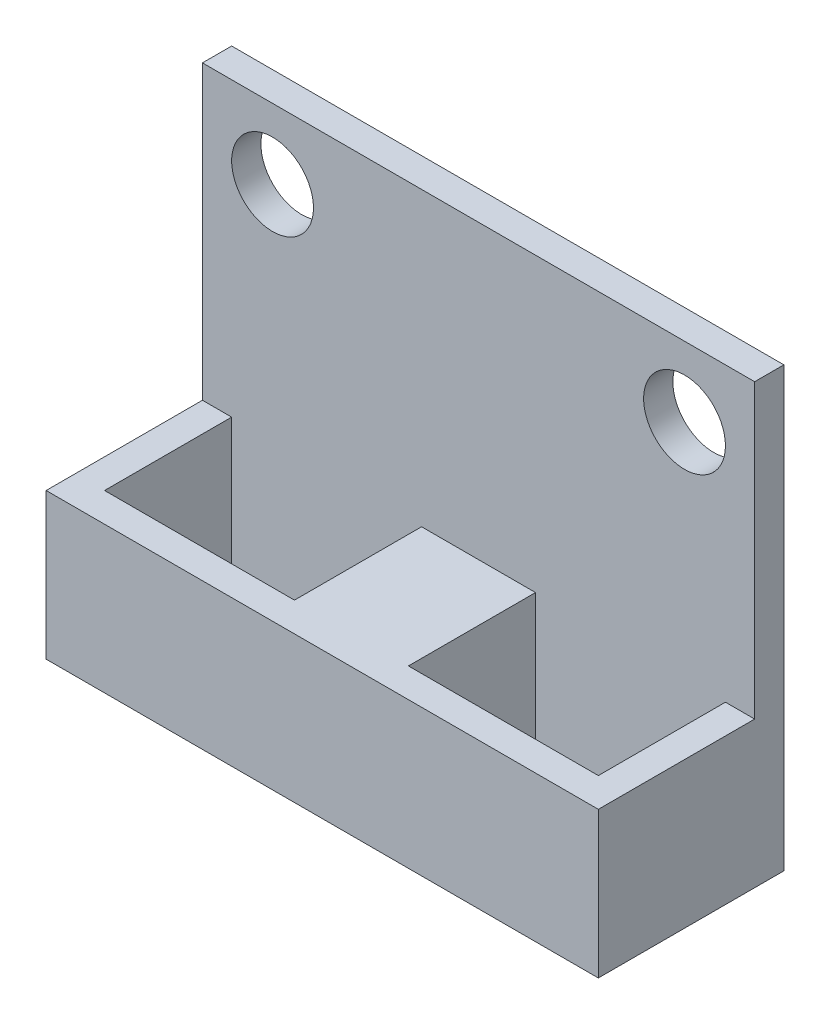
from build123d import *

# Parameters (mm, degrees)
SKETCH1_W           = 18.9
SKETCH1_H           = 6.35
SKETCH1_W_2         = 6.5
SKETCH1_H_2         = 4.35
BOSS_EXTRUDE1_DEPTH = 5
SKETCH2_W           = 18.9
SKETCH2_H           = 1
BOSS_EXTRUDE2_DEPTH = 10
SKETCH3_R           = 1.4
CUT_EXTRUDE1_DEPTH  = 2


with BuildPart() as part:
    # Sketch1 → Boss-Extrude1 (new body)
    with BuildSketch(Plane(origin=(0, 0, 0), x_dir=(1, 0, 0), z_dir=(0, 1, 0))):
        Rectangle(SKETCH1_W, SKETCH1_H)
        with Locations((-5.2, 0)):
            Rectangle(SKETCH1_W_2, SKETCH1_H_2, mode=Mode.SUBTRACT)
        with Locations((5.2, 0)):
            Rectangle(SKETCH1_W_2, SKETCH1_H_2, mode=Mode.SUBTRACT)
    extrude(amount=BOSS_EXTRUDE1_DEPTH)

    # Sketch2 → Boss-Extrude2 (add)
    with BuildSketch(Plane(origin=(0, 5, 0), x_dir=(1, 0, 0), z_dir=(0, 1, 0))):
        with Locations((0, 2.675)):
            Rectangle(SKETCH2_W, SKETCH2_H)
    extrude(amount=BOSS_EXTRUDE2_DEPTH)

    # Sketch3 → Cut-Extrude1 (cut, through all)
    with BuildSketch(Plane.XY.offset(-2.175)):
        with Locations((7.05, 12.6)):
            Circle(SKETCH3_R)
        with Locations((-7.05, 12.6)):
            Circle(SKETCH3_R)
    extrude(amount=-CUT_EXTRUDE1_DEPTH, mode=Mode.SUBTRACT)


solid = part.part
